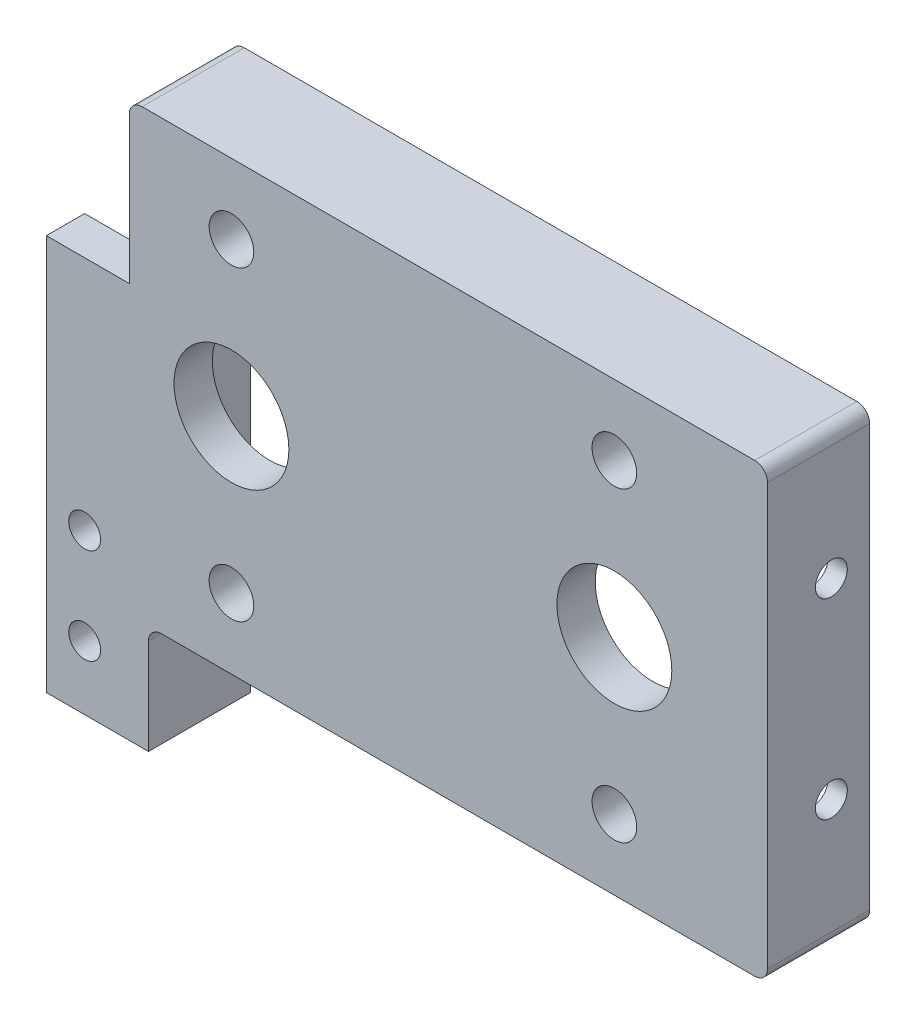
from build123d import *

# Parameters (mm, degrees)
SKETCH1_W           = 100
SKETCH1_H           = 64
BOSS_EXTRUDE1_DEPTH = 6
SKETCH2_R           = 9
SKETCH2_R_2         = 3.5
CUT_EXTRUDE1_DEPTH  = 10
LPATTERN1_COUNT     = 2
LPATTERN1_PITCH     = 60
BOSS_EXTRUDE2_DEPTH = 10
SKETCH4_W           = 6
SKETCH4_H           = 6
BOSS_EXTRUDE3_DEPTH = 20
SKETCH5_W           = 97
SKETCH5_H           = 16
BOSS_EXTRUDE4_DEPTH = 3
LPATTERN4_COUNT     = 2
LPATTERN4_PITCH     = 67
SKETCH6_W           = 16
SKETCH6_H           = 70
BOSS_EXTRUDE5_DEPTH = 3
SKETCH7_W           = 5.405235292
SKETCH7_H           = 22
CUT_EXTRUDE2_DEPTH  = 6
SKETCH8_W           = 6
SKETCH8_H           = 62
BOSS_EXTRUDE6_DEPTH = 10
SKETCH9_R           = 2.5
CUT_EXTRUDE3_DEPTH  = 10
LPATTERN5_COUNT     = 2
LPATTERN5_PITCH     = 15
FILLET1_R           = 2
SKETCH10_R          = 2.5
CUT_EXTRUDE4_DEPTH  = 10
LPATTERN6_COUNT     = 2
LPATTERN6_PITCH     = 30


with BuildPart() as part:
    # Sketch1 → Boss-Extrude1 (new body)
    with BuildSketch(Plane.XY):
        with Locations((-4.657534247, -15.767123288)):
            Rectangle(SKETCH1_W, SKETCH1_H)
    extrude(amount=BOSS_EXTRUDE1_DEPTH)

    # Sketch2 → Cut-Extrude1 (cut)
    with BuildSketch(Plane.XY.offset(6)):
        with Locations((-35.657534247, -15.767123288)):
            Circle(SKETCH2_R)
        with Locations((-35.657534247, 8.232876712)):
            Circle(SKETCH2_R_2)
        with Locations((-35.657534247, -39.767123288)):
            Circle(SKETCH2_R_2)
    cut_extrude1 = extrude(amount=-CUT_EXTRUDE1_DEPTH, mode=Mode.SUBTRACT)

    # LPattern1: Cut-Extrude1 ×2
    with Locations(*[(i * LPATTERN1_PITCH, 0, 0) for i in range(1, LPATTERN1_COUNT)]):
        add(cut_extrude1, mode=Mode.SUBTRACT)

    # Sketch3 → Boss-Extrude2 (add)
    with BuildSketch(Plane(origin=(0, 0, 0), x_dir=(-1, 0, 0), z_dir=(0, 0, -1))):
        Polygon((48.657534247, -47.767123288), (48.657534247, 16.232876712), (51.657534247, 16.232876712), (51.657534247, -47.767123288), (51.657534247, -67.767123288), (48.657534247, -67.767123288), align=None)
    extrude(amount=BOSS_EXTRUDE2_DEPTH)

    # Sketch4 → Boss-Extrude3 (add)
    with BuildSketch(Plane(origin=(0, -47.767123288, 0), x_dir=(-1, 0, 0), z_dir=(0, -1, 0))):
        with Locations((51.657534247, -3)):
            Rectangle(SKETCH4_W, SKETCH4_H)
    extrude(amount=BOSS_EXTRUDE3_DEPTH)

    # Sketch5 → Boss-Extrude4 (add)
    with BuildSketch(Plane(origin=(0, -47.767123288, 0), x_dir=(-1, 0, 0), z_dir=(0, -1, 0))):
        with Locations((3.157534247, 2)):
            Rectangle(SKETCH5_W, SKETCH5_H)
    boss_extrude4 = extrude(amount=BOSS_EXTRUDE4_DEPTH)

    # LPattern4: Boss-Extrude4 ×2
    with Locations(*[(0, i * LPATTERN4_PITCH, 0) for i in range(1, LPATTERN4_COUNT)]):
        add(boss_extrude4)

    # Sketch6 → Boss-Extrude5 (add)
    with BuildSketch(Plane(origin=(45.342465753, 0, 0), x_dir=(0, 0, -1), z_dir=(1, 0, 0))):
        with Locations((2, -15.767123288)):
            Rectangle(SKETCH6_W, SKETCH6_H)
    extrude(amount=BOSS_EXTRUDE5_DEPTH)

    # Sketch7 → Cut-Extrude2 (cut)
    with BuildSketch(Plane(origin=(0, 0, 0), x_dir=(-1, 0, 0), z_dir=(0, 0, -1))):
        with Locations((54.360151893, 5.232876712)):
            Rectangle(SKETCH7_W, SKETCH7_H)
    extrude(amount=-CUT_EXTRUDE2_DEPTH, mode=Mode.SUBTRACT)

    # Sketch8 → Boss-Extrude6 (add)
    with BuildSketch(Plane.ZY.offset(54.657534247)):
        with Locations((3, -36.767123288)):
            Rectangle(SKETCH8_W, SKETCH8_H)
    extrude(amount=BOSS_EXTRUDE6_DEPTH)

    # Sketch9 → Cut-Extrude3 (cut)
    with BuildSketch(Plane(origin=(0, 0, 0), x_dir=(-1, 0, 0), z_dir=(0, 0, -1))):
        with Locations((58.657534247, -57.767123288)):
            Circle(SKETCH9_R)
    cut_extrude3 = extrude(amount=-CUT_EXTRUDE3_DEPTH, mode=Mode.SUBTRACT)

    # LPattern5: Cut-Extrude3 ×2
    with Locations(*[(0, i * LPATTERN5_PITCH, 0) for i in range(1, LPATTERN5_COUNT)]):
        add(cut_extrude3, mode=Mode.SUBTRACT)

    # Fillet1
    fillet1_edges = [part.edges().sort_by_distance(p)[0] for p in [
        (-51.657534247, 19.232876712, -2),
        (48.342465753, -50.767123288, -2),
        (48.342465753, 19.232876712, -2),
        (-48.657534247, -50.767123288, -2),
    ]]
    fillet(fillet1_edges, radius=FILLET1_R)

    # Sketch10 → Cut-Extrude4 (cut)
    with BuildSketch(Plane(origin=(48.342465753, 0, 0), x_dir=(0, 0, -1), z_dir=(1, 0, 0))):
        with Locations((4, -0.767123288)):
            Circle(SKETCH10_R)
    cut_extrude4 = extrude(amount=-CUT_EXTRUDE4_DEPTH, mode=Mode.SUBTRACT)

    # LPattern6: Cut-Extrude4 ×2
    with Locations(*[(0, -i * LPATTERN6_PITCH, 0) for i in range(1, LPATTERN6_COUNT)]):
        add(cut_extrude4, mode=Mode.SUBTRACT)


solid = part.part
